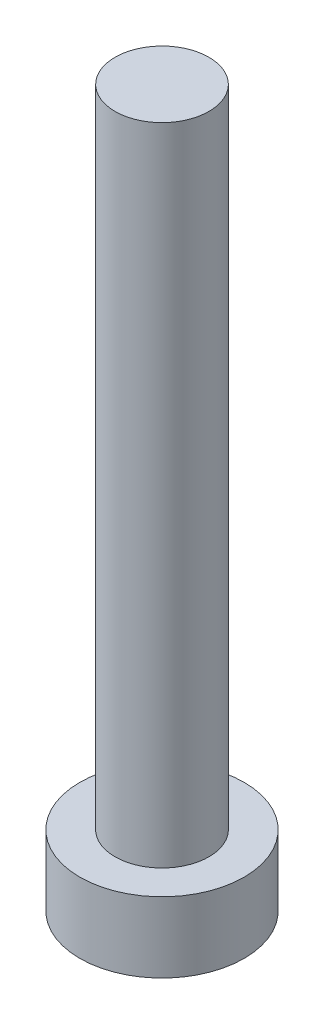
from build123d import *

# Parameters (mm, degrees)
SKETCH1_R           = 7
BOSS_EXTRUDE1_DEPTH = 6
SKETCH2_R           = 4
BOSS_EXTRUDE2_DEPTH = 55


with BuildPart() as part:
    # Sketch1 → Boss-Extrude1 (new body)
    with BuildSketch(Plane(origin=(0, 0, 0), x_dir=(1, 0, 0), z_dir=(0, 1, 0))):
        Circle(SKETCH1_R)
    extrude(amount=BOSS_EXTRUDE1_DEPTH)

    # Sketch2 → Boss-Extrude2 (add)
    with BuildSketch(Plane(origin=(0, 6, 0), x_dir=(1, 0, 0), z_dir=(0, 1, 0))):
        Circle(SKETCH2_R)
    extrude(amount=BOSS_EXTRUDE2_DEPTH)


solid = part.part
